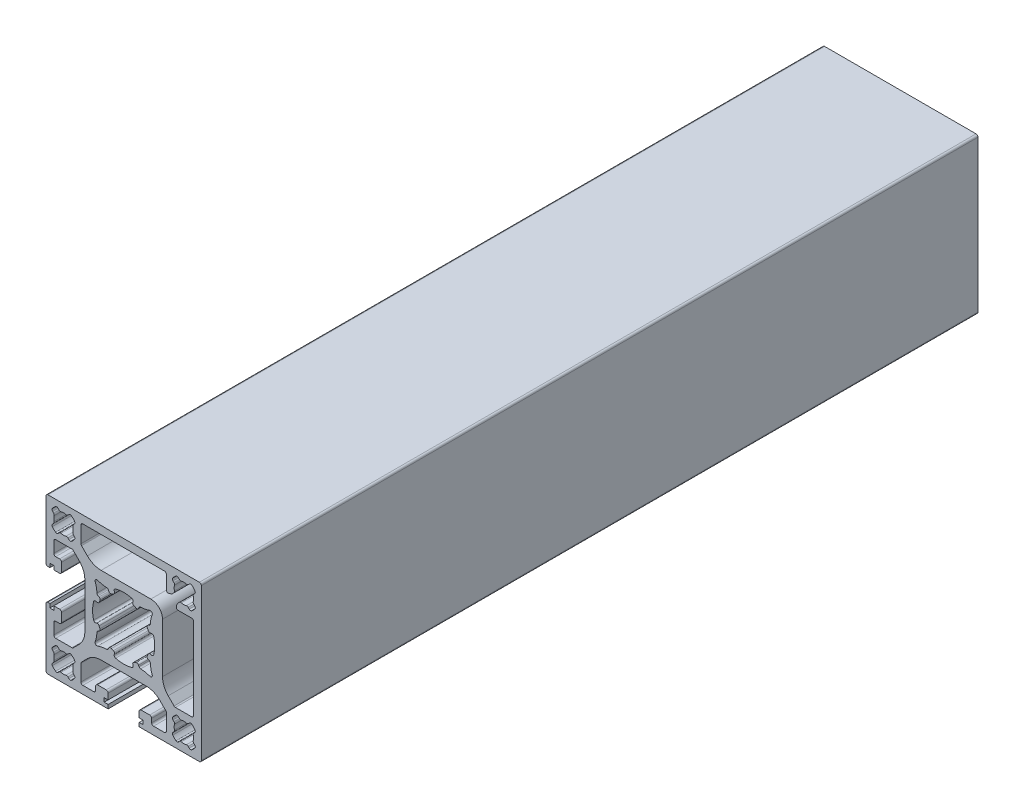
from build123d import *

# Parameters (mm, degrees)
EXTRUDE1_DEPTH = 200


with BuildPart() as part:
    # Sketch1 → Extrude1 (new body)
    with BuildSketch(Plane.XY):
        with BuildLine():
            Line((20, -4.5), (20, 4.5))
            Line((20, 4.5), (20, 19.5))
            ThreePointArc((20, 19.5), (19.853553391, 19.853553391), (19.5, 20))
            Line((19.5, 20), (4, 20))
            Line((4, 20), (-4, 20))
            Line((-4, 20), (-19.5, 20))
            ThreePointArc((-19.5, 20), (-19.853553391, 19.853553391), (-20, 19.5))
            Line((-20, 19.5), (-20, 4.5))
            ThreePointArc((-20, 4.5), (-19.853553391, 4.146446609), (-19.5, 4))
            Line((-19.5, 4), (-19, 4))
            Line((-19, 4), (-19, 5))
            Line((-19, 5), (-18, 5))
            Line((-18, 5), (-18, 4))
            Line((-18, 4), (-16.5, 4))
            ThreePointArc((-16.5, 4), (-16.146446609, 4.146446609), (-16, 4.5))
            Line((-16, 4.5), (-16, 6.7))
            ThreePointArc((-16, 6.7), (-16.146446609, 7.053553391), (-16.5, 7.2))
            Line((-16.5, 7.2), (-17.5, 7.2))
            ThreePointArc((-17.5, 7.2), (-17.853553391, 7.346446609), (-18, 7.7))
            Line((-18, 7.7), (-18, 10.5))
            ThreePointArc((-18, 10.5), (-17.853553391, 10.853553391), (-17.5, 11))
            Line((-17.5, 11), (-16, 11))
            Line((-16, 11), (-13.328427125, 11))
            ThreePointArc((-13.328427125, 11), (-13.137085409, 10.961939766), (-12.974873734, 10.853553391))
            Line((-12.974873734, 10.853553391), (-11.464466094, 9.343145751))
            ThreePointArc((-11.464466094, 9.343145751), (-10.380602337, 7.721029006), (-10, 5.807611845))
            Line((-10, 5.807611845), (-10, -5.807611845))
            ThreePointArc((-10, -5.807611845), (-10.380602337, -7.721029006), (-11.464466094, -9.343145751))
            Line((-11.464466094, -9.343145751), (-12.974873734, -10.853553391))
            ThreePointArc((-12.974873734, -10.853553391), (-13.137085409, -10.961939766), (-13.328427125, -11))
            Line((-13.328427125, -11), (-16, -11))
            Line((-16, -11), (-17.5, -11))
            ThreePointArc((-17.5, -11), (-17.853553391, -10.853553391), (-18, -10.5))
            Line((-18, -10.5), (-18, -7.7))
            ThreePointArc((-18, -7.7), (-17.853553391, -7.346446609), (-17.5, -7.2))
            Line((-17.5, -7.2), (-16.5, -7.2))
            ThreePointArc((-16.5, -7.2), (-16.146446609, -7.053553391), (-16, -6.7))
            Line((-16, -6.7), (-16, -4.5))
            ThreePointArc((-16, -4.5), (-16.146446609, -4.146446609), (-16.5, -4))
            Line((-16.5, -4), (-18, -4))
            Line((-18, -4), (-18, -5))
            Line((-18, -5), (-19, -5))
            Line((-19, -5), (-19, -4))
            Line((-19, -4), (-19.5, -4))
            ThreePointArc((-19.5, -4), (-19.853553391, -4.146446609), (-20, -4.5))
            Line((-20, -4.5), (-20, -19.5))
            ThreePointArc((-20, -19.5), (-19.853553391, -19.853553391), (-19.5, -20))
            Line((-19.5, -20), (-4, -20))
            Line((-4, -20), (-4, -19))
            Line((-4, -19), (-5, -19))
            Line((-5, -19), (-5, -18))
            Line((-5, -18), (-4, -18))
            Line((-4, -18), (-4, -16.5))
            ThreePointArc((-4, -16.5), (-4.146446609, -16.146446609), (-4.5, -16))
            Line((-4.5, -16), (-6.7, -16))
            ThreePointArc((-6.7, -16), (-7.053553391, -16.146446609), (-7.2, -16.5))
            Line((-7.2, -16.5), (-7.2, -17.5))
            ThreePointArc((-7.2, -17.5), (-7.346446609, -17.853553391), (-7.7, -18))
            Line((-7.7, -18), (-10.5, -18))
            ThreePointArc((-10.5, -18), (-10.853553391, -17.853553391), (-11, -17.5))
            Line((-11, -17.5), (-11, -13.328427125))
            ThreePointArc((-11, -13.328427125), (-10.961939766, -13.137085409), (-10.853553391, -12.974873734))
            Line((-10.853553391, -12.974873734), (-9.343145751, -11.464466094))
            ThreePointArc((-9.343145751, -11.464466094), (-7.721029006, -10.380602337), (-5.807611845, -10))
            Line((-5.807611845, -10), (5.807611845, -10))
            ThreePointArc((5.807611845, -10), (7.721029006, -10.380602337), (9.343145751, -11.464466094))
            Line((9.343145751, -11.464466094), (10.853553391, -12.974873734))
            ThreePointArc((10.853553391, -12.974873734), (10.961939766, -13.137085409), (11, -13.328427125))
            Line((11, -13.328427125), (11, -17.5))
            ThreePointArc((11, -17.5), (10.853553391, -17.853553391), (10.5, -18))
            Line((10.5, -18), (7.7, -18))
            ThreePointArc((7.7, -18), (7.346446609, -17.853553391), (7.2, -17.5))
            Line((7.2, -17.5), (7.2, -16.5))
            ThreePointArc((7.2, -16.5), (7.053553391, -16.146446609), (6.7, -16))
            Line((6.7, -16), (4.5, -16))
            ThreePointArc((4.5, -16), (4.146446609, -16.146446609), (4, -16.5))
            Line((4, -16.5), (4, -18))
            Line((4, -18), (5, -18))
            Line((5, -18), (5, -19))
            Line((5, -19), (4, -19))
            Line((4, -19), (4, -20))
            Line((4, -20), (19.5, -20))
            ThreePointArc((19.5, -20), (19.853553391, -19.853553391), (20, -19.5))
            Line((20, -19.5), (20, -4.5))
        make_face()
        with BuildLine():
            Line((11, 17.5), (11, 14.037650042))
            ThreePointArc((11, 14.037650042), (11.211899944, 13.628995717), (11.66799343, 13.566716706))
            Line((11.66799343, 13.566716706), (12.421184974, 13.835398536))
            Line((12.421184974, 13.835398536), (12.701243152, 14.115456715))
            Line((12.701243152, 14.115456715), (12.955775912, 14.369989474))
            ThreePointArc((12.955775912, 14.369989474), (13.085185434, 14.594133342), (13.085185434, 14.852952387))
            ThreePointArc((13.085185434, 14.852952387), (13, 15.5), (13.085185434, 16.147047613))
            ThreePointArc((13.085185434, 16.147047613), (13.085185434, 16.405866658), (12.955775912, 16.630010526))
            Line((12.955775912, 16.630010526), (12.701243152, 16.884543285))
            ThreePointArc((12.701243152, 16.884543285), (12.556547948, 17.196283546), (12.647262634, 17.527779455))
            ThreePointArc((12.647262634, 17.527779455), (13.025126266, 17.974873734), (13.472220545, 18.352737366))
            ThreePointArc((13.472220545, 18.352737366), (13.803716454, 18.443452052), (14.115456715, 18.298756848))
            Line((14.115456715, 18.298756848), (14.369989474, 18.044224088))
            ThreePointArc((14.369989474, 18.044224088), (14.594133342, 17.914814566), (14.852952387, 17.914814566))
            ThreePointArc((14.852952387, 17.914814566), (15.5, 18), (16.147047613, 17.914814566))
            ThreePointArc((16.147047613, 17.914814566), (16.405866658, 17.914814566), (16.630010526, 18.044224088))
            Line((16.630010526, 18.044224088), (16.884543285, 18.298756848))
            ThreePointArc((16.884543285, 18.298756848), (17.196283546, 18.443452052), (17.527779455, 18.352737366))
            ThreePointArc((17.527779455, 18.352737366), (17.974873734, 17.974873734), (18.352737366, 17.527779455))
            ThreePointArc((18.352737366, 17.527779455), (18.443452052, 17.196283546), (18.298756848, 16.884543285))
            Line((18.298756848, 16.884543285), (18.044224088, 16.630010526))
            ThreePointArc((18.044224088, 16.630010526), (17.914814566, 16.405866658), (17.914814566, 16.147047613))
            ThreePointArc((17.914814566, 16.147047613), (18, 15.5), (17.914814566, 14.852952387))
            ThreePointArc((17.914814566, 14.852952387), (17.914814566, 14.594133342), (18.044224088, 14.369989474))
            Line((18.044224088, 14.369989474), (18.298756848, 14.115456715))
            ThreePointArc((18.298756848, 14.115456715), (18.443452052, 13.803716454), (18.352737366, 13.472220545))
            ThreePointArc((18.352737366, 13.472220545), (17.974873734, 13.025126266), (17.527779455, 12.647262634))
            ThreePointArc((17.527779455, 12.647262634), (17.196283546, 12.556547948), (16.884543285, 12.701243152))
            Line((16.884543285, 12.701243152), (16.630010526, 12.955775912))
            ThreePointArc((16.630010526, 12.955775912), (16.405866658, 13.085185434), (16.147047613, 13.085185434))
            ThreePointArc((16.147047613, 13.085185434), (15.5, 13), (14.852952387, 13.085185434))
            ThreePointArc((14.852952387, 13.085185434), (14.594133342, 13.085185434), (14.369989474, 12.955775912))
            Line((14.369989474, 12.955775912), (14.115456715, 12.701243152))
            Line((14.115456715, 12.701243152), (13.835398536, 12.421184974))
            Line((13.835398536, 12.421184974), (13.566716706, 11.66799343))
            ThreePointArc((13.566716706, 11.66799343), (13.628995717, 11.211899944), (14.037650042, 11))
            Line((14.037650042, 11), (16, 11))
            Line((16, 11), (17.5, 11))
            ThreePointArc((17.5, 11), (17.853553391, 10.853553391), (18, 10.5))
            Line((18, 10.5), (18, 7.7))
            Line((18, 7.7), (18, -7.7))
            Line((18, -7.7), (18, -10.5))
            ThreePointArc((18, -10.5), (17.853553391, -10.853553391), (17.5, -11))
            Line((17.5, -11), (16, -11))
            Line((16, -11), (13.328427125, -11))
            ThreePointArc((13.328427125, -11), (13.137085409, -10.961939766), (12.974873734, -10.853553391))
            Line((12.974873734, -10.853553391), (11.464466094, -9.343145751))
            ThreePointArc((11.464466094, -9.343145751), (10.380602337, -7.721029006), (10, -5.807611845))
            Line((10, -5.807611845), (10, 5.807611845))
            Line((10, 5.807611845), (10, 7))
            ThreePointArc((10, 7), (9.121320344, 9.121320344), (7, 10))
            Line((7, 10), (5.807611845, 10))
            Line((5.807611845, 10), (-5.807611845, 10))
            ThreePointArc((-5.807611845, 10), (-7.721029006, 10.380602337), (-9.343145751, 11.464466094))
            Line((-9.343145751, 11.464466094), (-10.853553391, 12.974873734))
            ThreePointArc((-10.853553391, 12.974873734), (-10.961939766, 13.137085409), (-11, 13.328427125))
            Line((-11, 13.328427125), (-11, 17.5))
            ThreePointArc((-11, 17.5), (-10.853553391, 17.853553391), (-10.5, 18))
            Line((-10.5, 18), (-7.7, 18))
            Line((-7.7, 18), (7.7, 18))
            Line((7.7, 18), (10.5, 18))
            ThreePointArc((10.5, 18), (10.853553391, 17.853553391), (11, 17.5))
        make_face(mode=Mode.SUBTRACT)
        with BuildLine():
            Line((-3.955481277, 6.589595707), (-3.828701916, 6.317716489))
            ThreePointArc((-3.828701916, 6.317716489), (-3.536931765, 6.055786476), (-3.145918905, 6.084874217))
            ThreePointArc((-3.145918905, 6.084874217), (-2.894935093, 6.208208341), (-2.639126388, 6.321195449))
            ThreePointArc((-2.639126388, 6.321195449), (-2.365505664, 6.602031438), (-2.378609457, 6.993905708))
            Line((-2.378609457, 6.993905708), (-2.396612625, 7.032513628))
            ThreePointArc((-2.396612625, 7.032513628), (-2.396646397, 7.455059452), (-2.073022647, 7.726744276))
            ThreePointArc((-2.073022647, 7.726744276), (0, 8), (2.073022647, 7.726744276))
            ThreePointArc((2.073022647, 7.726744276), (2.396646397, 7.455059452), (2.396612625, 7.032513628))
            Line((2.396612625, 7.032513628), (2.378609457, 6.993905708))
            ThreePointArc((2.378609457, 6.993905708), (2.365505664, 6.602031438), (2.639126388, 6.321195449))
            ThreePointArc((2.639126388, 6.321195449), (2.894935093, 6.208208341), (3.145918905, 6.084874217))
            ThreePointArc((3.145918905, 6.084874217), (3.536931765, 6.055786476), (3.828701916, 6.317716489))
            Line((3.828701916, 6.317716489), (3.955481277, 6.589595707))
            ThreePointArc((3.955481277, 6.589595707), (4.133992703, 6.796104137), (4.394360834, 6.878082778))
            ThreePointArc((4.394360834, 6.878082778), (5.563636578, 7.01042661), (6.694221632, 7.336767065))
            ThreePointArc((6.694221632, 7.336767065), (7.225849065, 7.223762843), (7.340283605, 6.692441455))
            ThreePointArc((7.340283605, 6.692441455), (7.017377418, 5.56296621), (6.887896152, 4.395397224))
            ThreePointArc((6.887896152, 4.395397224), (6.806059945, 4.134233802), (6.59898837, 3.955278888))
            Line((6.59898837, 3.955278888), (6.319893727, 3.825428413))
            ThreePointArc((6.319893727, 3.825428413), (6.057684603, 3.533805493), (6.086538329, 3.142698072))
            ThreePointArc((6.086538329, 3.142698072), (6.20973961, 2.891649006), (6.322591322, 2.635780524))
            ThreePointArc((6.322591322, 2.635780524), (6.603204408, 2.362041487), (6.995011811, 2.374836943))
            Line((6.995011811, 2.374836943), (7.043041461, 2.397183029))
            ThreePointArc((7.043041461, 2.397183029), (7.46545934, 2.396911359), (7.736919279, 2.073265813))
            ThreePointArc((7.736919279, 2.073265813), (8.009890827, 0), (7.736919279, -2.073265813))
            ThreePointArc((7.736919279, -2.073265813), (7.46545934, -2.396911359), (7.043041461, -2.397183029))
            Line((7.043041461, -2.397183029), (6.995011811, -2.374836943))
            ThreePointArc((6.995011811, -2.374836943), (6.603204408, -2.362041487), (6.322591322, -2.635780524))
            ThreePointArc((6.322591322, -2.635780524), (6.20973961, -2.891649006), (6.086538329, -3.142698072))
            ThreePointArc((6.086538329, -3.142698072), (6.057684603, -3.533805493), (6.319893727, -3.825428413))
            Line((6.319893727, -3.825428413), (6.59898837, -3.955278888))
            ThreePointArc((6.59898837, -3.955278888), (6.806059945, -4.134233802), (6.887896152, -4.395397224))
            ThreePointArc((6.887896152, -4.395397224), (7.017377418, -5.56296621), (7.340283605, -6.692441455))
            ThreePointArc((7.340283605, -6.692441455), (7.225849065, -7.223762843), (6.694221632, -7.336767065))
            ThreePointArc((6.694221632, -7.336767065), (5.563636578, -7.01042661), (4.394360834, -6.878082778))
            ThreePointArc((4.394360834, -6.878082778), (4.133992703, -6.796104137), (3.955481277, -6.589595707))
            Line((3.955481277, -6.589595707), (3.828701916, -6.317716489))
            ThreePointArc((3.828701916, -6.317716489), (3.536931765, -6.055786476), (3.145918905, -6.084874217))
            ThreePointArc((3.145918905, -6.084874217), (2.894935093, -6.208208341), (2.639126388, -6.321195449))
            ThreePointArc((2.639126388, -6.321195449), (2.365505664, -6.602031438), (2.378609457, -6.993905708))
            Line((2.378609457, -6.993905708), (2.396612625, -7.032513628))
            ThreePointArc((2.396612625, -7.032513628), (2.396646397, -7.455059452), (2.073022647, -7.726744276))
            ThreePointArc((2.073022647, -7.726744276), (0, -8), (-2.073022647, -7.726744276))
            ThreePointArc((-2.073022647, -7.726744276), (-2.396646397, -7.455059452), (-2.396612625, -7.032513628))
            Line((-2.396612625, -7.032513628), (-2.378609457, -6.993905708))
            ThreePointArc((-2.378609457, -6.993905708), (-2.365505664, -6.602031438), (-2.639126388, -6.321195449))
            ThreePointArc((-2.639126388, -6.321195449), (-2.894935093, -6.208208341), (-3.145918905, -6.084874217))
            ThreePointArc((-3.145918905, -6.084874217), (-3.536931765, -6.055786476), (-3.828701916, -6.317716489))
            Line((-3.828701916, -6.317716489), (-3.955481277, -6.589595707))
            ThreePointArc((-3.955481277, -6.589595707), (-4.133992703, -6.796104137), (-4.394360834, -6.878082778))
            ThreePointArc((-4.394360834, -6.878082778), (-5.563636578, -7.01042661), (-6.694221632, -7.336767065))
            ThreePointArc((-6.694221632, -7.336767065), (-7.225849065, -7.223762843), (-7.340283605, -6.692441455))
            ThreePointArc((-7.340283605, -6.692441455), (-7.017377418, -5.56296621), (-6.887896152, -4.395397224))
            ThreePointArc((-6.887896152, -4.395397224), (-6.806059945, -4.134233802), (-6.59898837, -3.955278888))
            Line((-6.59898837, -3.955278888), (-6.319893727, -3.825428413))
            ThreePointArc((-6.319893727, -3.825428413), (-6.057684603, -3.533805493), (-6.086538329, -3.142698072))
            ThreePointArc((-6.086538329, -3.142698072), (-6.20973961, -2.891649006), (-6.322591322, -2.635780524))
            ThreePointArc((-6.322591322, -2.635780524), (-6.603204408, -2.362041487), (-6.995011811, -2.374836943))
            Line((-6.995011811, -2.374836943), (-7.043041461, -2.397183029))
            ThreePointArc((-7.043041461, -2.397183029), (-7.46545934, -2.396911359), (-7.736919279, -2.073265813))
            ThreePointArc((-7.736919279, -2.073265813), (-8.009890827, 0), (-7.736919279, 2.073265813))
            ThreePointArc((-7.736919279, 2.073265813), (-7.46545934, 2.396911359), (-7.043041461, 2.397183029))
            Line((-7.043041461, 2.397183029), (-6.995011811, 2.374836943))
            ThreePointArc((-6.995011811, 2.374836943), (-6.603204408, 2.362041487), (-6.322591322, 2.635780524))
            ThreePointArc((-6.322591322, 2.635780524), (-6.20973961, 2.891649006), (-6.086538329, 3.142698072))
            ThreePointArc((-6.086538329, 3.142698072), (-6.057684603, 3.533805493), (-6.319893727, 3.825428413))
            Line((-6.319893727, 3.825428413), (-6.59898837, 3.955278888))
            ThreePointArc((-6.59898837, 3.955278888), (-6.806059945, 4.134233802), (-6.887896152, 4.395397224))
            ThreePointArc((-6.887896152, 4.395397224), (-7.017377418, 5.56296621), (-7.340283605, 6.692441455))
            ThreePointArc((-7.340283605, 6.692441455), (-7.225849065, 7.223762843), (-6.694221632, 7.336767065))
            ThreePointArc((-6.694221632, 7.336767065), (-5.563636578, 7.01042661), (-4.394360834, 6.878082778))
            ThreePointArc((-4.394360834, 6.878082778), (-4.133992703, 6.796104137), (-3.955481277, 6.589595707))
        make_face(mode=Mode.SUBTRACT)
        with BuildLine():
            Line((-14.115456715, 18.298756848), (-14.369989474, 18.044224088))
            ThreePointArc((-14.369989474, 18.044224088), (-14.594133342, 17.914814566), (-14.852952387, 17.914814566))
            ThreePointArc((-14.852952387, 17.914814566), (-15.5, 18), (-16.147047613, 17.914814566))
            ThreePointArc((-16.147047613, 17.914814566), (-16.405866658, 17.914814566), (-16.630010526, 18.044224088))
            Line((-16.630010526, 18.044224088), (-16.884543285, 18.298756848))
            ThreePointArc((-16.884543285, 18.298756848), (-17.196283546, 18.443452052), (-17.527779455, 18.352737366))
            ThreePointArc((-17.527779455, 18.352737366), (-17.974873734, 17.974873734), (-18.352737366, 17.527779455))
            ThreePointArc((-18.352737366, 17.527779455), (-18.443452052, 17.196283546), (-18.298756848, 16.884543285))
            Line((-18.298756848, 16.884543285), (-18.044224088, 16.630010526))
            ThreePointArc((-18.044224088, 16.630010526), (-17.914814566, 16.405866658), (-17.914814566, 16.147047613))
            ThreePointArc((-17.914814566, 16.147047613), (-18, 15.5), (-17.914814566, 14.852952387))
            ThreePointArc((-17.914814566, 14.852952387), (-17.914814566, 14.594133342), (-18.044224088, 14.369989474))
            Line((-18.044224088, 14.369989474), (-18.298756848, 14.115456715))
            ThreePointArc((-18.298756848, 14.115456715), (-18.443452052, 13.803716454), (-18.352737366, 13.472220545))
            ThreePointArc((-18.352737366, 13.472220545), (-17.974873734, 13.025126266), (-17.527779455, 12.647262634))
            ThreePointArc((-17.527779455, 12.647262634), (-17.196283546, 12.556547948), (-16.884543285, 12.701243152))
            Line((-16.884543285, 12.701243152), (-16.630010526, 12.955775912))
            ThreePointArc((-16.630010526, 12.955775912), (-16.405866658, 13.085185434), (-16.147047613, 13.085185434))
            ThreePointArc((-16.147047613, 13.085185434), (-15.5, 13), (-14.852952387, 13.085185434))
            ThreePointArc((-14.852952387, 13.085185434), (-14.594133342, 13.085185434), (-14.369989474, 12.955775912))
            Line((-14.369989474, 12.955775912), (-14.115456715, 12.701243152))
            ThreePointArc((-14.115456715, 12.701243152), (-13.803716454, 12.556547948), (-13.472220545, 12.647262634))
            ThreePointArc((-13.472220545, 12.647262634), (-13.025126266, 13.025126266), (-12.647262634, 13.472220545))
            ThreePointArc((-12.647262634, 13.472220545), (-12.556547948, 13.803716454), (-12.701243152, 14.115456715))
            Line((-12.701243152, 14.115456715), (-12.955775912, 14.369989474))
            ThreePointArc((-12.955775912, 14.369989474), (-13.085185434, 14.594133342), (-13.085185434, 14.852952387))
            ThreePointArc((-13.085185434, 14.852952387), (-13, 15.5), (-13.085185434, 16.147047613))
            ThreePointArc((-13.085185434, 16.147047613), (-13.085185434, 16.405866658), (-12.955775912, 16.630010526))
            Line((-12.955775912, 16.630010526), (-12.701243152, 16.884543285))
            ThreePointArc((-12.701243152, 16.884543285), (-12.556547948, 17.196283546), (-12.647262634, 17.527779455))
            ThreePointArc((-12.647262634, 17.527779455), (-13.025126266, 17.974873734), (-13.472220545, 18.352737366))
            ThreePointArc((-13.472220545, 18.352737366), (-13.803716454, 18.443452052), (-14.115456715, 18.298756848))
        make_face(mode=Mode.SUBTRACT)
        with BuildLine():
            Line((14.115456715, -18.298756848), (14.369989474, -18.044224088))
            ThreePointArc((14.369989474, -18.044224088), (14.594133342, -17.914814566), (14.852952387, -17.914814566))
            ThreePointArc((14.852952387, -17.914814566), (15.5, -18), (16.147047613, -17.914814566))
            ThreePointArc((16.147047613, -17.914814566), (16.405866658, -17.914814566), (16.630010526, -18.044224088))
            Line((16.630010526, -18.044224088), (16.884543285, -18.298756848))
            ThreePointArc((16.884543285, -18.298756848), (17.196283546, -18.443452052), (17.527779455, -18.352737366))
            ThreePointArc((17.527779455, -18.352737366), (17.974873734, -17.974873734), (18.352737366, -17.527779455))
            ThreePointArc((18.352737366, -17.527779455), (18.443452052, -17.196283546), (18.298756848, -16.884543285))
            Line((18.298756848, -16.884543285), (18.044224088, -16.630010526))
            ThreePointArc((18.044224088, -16.630010526), (17.914814566, -16.405866658), (17.914814566, -16.147047613))
            ThreePointArc((17.914814566, -16.147047613), (18, -15.5), (17.914814566, -14.852952387))
            ThreePointArc((17.914814566, -14.852952387), (17.914814566, -14.594133342), (18.044224088, -14.369989474))
            Line((18.044224088, -14.369989474), (18.298756848, -14.115456715))
            ThreePointArc((18.298756848, -14.115456715), (18.443452052, -13.803716454), (18.352737366, -13.472220545))
            ThreePointArc((18.352737366, -13.472220545), (17.974873734, -13.025126266), (17.527779455, -12.647262634))
            ThreePointArc((17.527779455, -12.647262634), (17.196283546, -12.556547948), (16.884543285, -12.701243152))
            Line((16.884543285, -12.701243152), (16.630010526, -12.955775912))
            ThreePointArc((16.630010526, -12.955775912), (16.405866658, -13.085185434), (16.147047613, -13.085185434))
            ThreePointArc((16.147047613, -13.085185434), (15.5, -13), (14.852952387, -13.085185434))
            ThreePointArc((14.852952387, -13.085185434), (14.594133342, -13.085185434), (14.369989474, -12.955775912))
            Line((14.369989474, -12.955775912), (14.115456715, -12.701243152))
            ThreePointArc((14.115456715, -12.701243152), (13.803716454, -12.556547948), (13.472220545, -12.647262634))
            ThreePointArc((13.472220545, -12.647262634), (13.025126266, -13.025126266), (12.647262634, -13.472220545))
            ThreePointArc((12.647262634, -13.472220545), (12.556547948, -13.803716454), (12.701243152, -14.115456715))
            Line((12.701243152, -14.115456715), (12.955775912, -14.369989474))
            ThreePointArc((12.955775912, -14.369989474), (13.085185434, -14.594133342), (13.085185434, -14.852952387))
            ThreePointArc((13.085185434, -14.852952387), (13, -15.5), (13.085185434, -16.147047613))
            ThreePointArc((13.085185434, -16.147047613), (13.085185434, -16.405866658), (12.955775912, -16.630010526))
            Line((12.955775912, -16.630010526), (12.701243152, -16.884543285))
            ThreePointArc((12.701243152, -16.884543285), (12.556547948, -17.196283546), (12.647262634, -17.527779455))
            ThreePointArc((12.647262634, -17.527779455), (13.025126266, -17.974873734), (13.472220545, -18.352737366))
            ThreePointArc((13.472220545, -18.352737366), (13.803716454, -18.443452052), (14.115456715, -18.298756848))
        make_face(mode=Mode.SUBTRACT)
        with BuildLine():
            Line((-14.115456715, -12.701243152), (-14.369989474, -12.955775912))
            ThreePointArc((-14.369989474, -12.955775912), (-14.594133342, -13.085185434), (-14.852952387, -13.085185434))
            ThreePointArc((-14.852952387, -13.085185434), (-15.5, -13), (-16.147047613, -13.085185434))
            ThreePointArc((-16.147047613, -13.085185434), (-16.405866658, -13.085185434), (-16.630010526, -12.955775912))
            Line((-16.630010526, -12.955775912), (-16.884543285, -12.701243152))
            ThreePointArc((-16.884543285, -12.701243152), (-17.196283546, -12.556547948), (-17.527779455, -12.647262634))
            ThreePointArc((-17.527779455, -12.647262634), (-17.974873734, -13.025126266), (-18.352737366, -13.472220545))
            ThreePointArc((-18.352737366, -13.472220545), (-18.443452052, -13.803716454), (-18.298756848, -14.115456715))
            Line((-18.298756848, -14.115456715), (-18.044224088, -14.369989474))
            ThreePointArc((-18.044224088, -14.369989474), (-17.914814566, -14.594133342), (-17.914814566, -14.852952387))
            ThreePointArc((-17.914814566, -14.852952387), (-18, -15.5), (-17.914814566, -16.147047613))
            ThreePointArc((-17.914814566, -16.147047613), (-17.914814566, -16.405866658), (-18.044224088, -16.630010526))
            Line((-18.044224088, -16.630010526), (-18.298756848, -16.884543285))
            ThreePointArc((-18.298756848, -16.884543285), (-18.443452052, -17.196283546), (-18.352737366, -17.527779455))
            ThreePointArc((-18.352737366, -17.527779455), (-17.974873734, -17.974873734), (-17.527779455, -18.352737366))
            ThreePointArc((-17.527779455, -18.352737366), (-17.196283546, -18.443452052), (-16.884543285, -18.298756848))
            Line((-16.884543285, -18.298756848), (-16.630010526, -18.044224088))
            ThreePointArc((-16.630010526, -18.044224088), (-16.405866658, -17.914814566), (-16.147047613, -17.914814566))
            ThreePointArc((-16.147047613, -17.914814566), (-15.5, -18), (-14.852952387, -17.914814566))
            ThreePointArc((-14.852952387, -17.914814566), (-14.594133342, -17.914814566), (-14.369989474, -18.044224088))
            Line((-14.369989474, -18.044224088), (-14.115456715, -18.298756848))
            ThreePointArc((-14.115456715, -18.298756848), (-13.803716454, -18.443452052), (-13.472220545, -18.352737366))
            ThreePointArc((-13.472220545, -18.352737366), (-13.025126266, -17.974873734), (-12.647262634, -17.527779455))
            ThreePointArc((-12.647262634, -17.527779455), (-12.556547948, -17.196283546), (-12.701243152, -16.884543285))
            Line((-12.701243152, -16.884543285), (-12.955775912, -16.630010526))
            ThreePointArc((-12.955775912, -16.630010526), (-13.085185434, -16.405866658), (-13.085185434, -16.147047613))
            ThreePointArc((-13.085185434, -16.147047613), (-13, -15.5), (-13.085185434, -14.852952387))
            ThreePointArc((-13.085185434, -14.852952387), (-13.085185434, -14.594133342), (-12.955775912, -14.369989474))
            Line((-12.955775912, -14.369989474), (-12.701243152, -14.115456715))
            ThreePointArc((-12.701243152, -14.115456715), (-12.556547948, -13.803716454), (-12.647262634, -13.472220545))
            ThreePointArc((-12.647262634, -13.472220545), (-13.025126266, -13.025126266), (-13.472220545, -12.647262634))
            ThreePointArc((-13.472220545, -12.647262634), (-13.803716454, -12.556547948), (-14.115456715, -12.701243152))
        make_face(mode=Mode.SUBTRACT)
    extrude(amount=-EXTRUDE1_DEPTH)


solid = part.part
